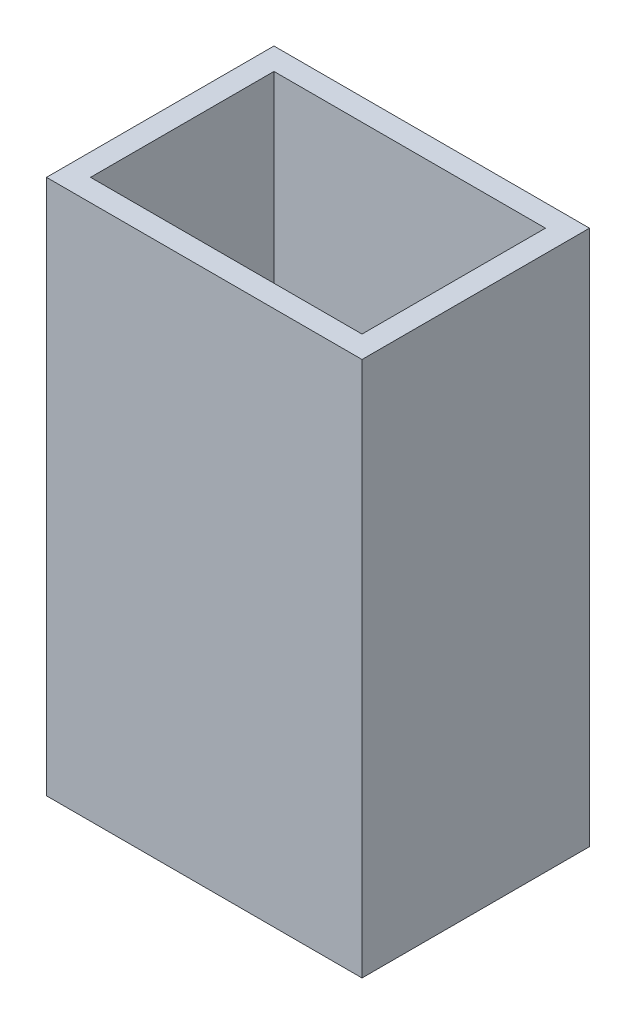
from build123d import *

# Parameters (mm, degrees)
SKETCH1_W            = 43
SKETCH1_H            = 31
BOSS_EXTRUDE1_DEPTH  = 3
BOSS_EXTRUDE2_START  = 3
SKETCH1_3_W          = 43
SKETCH1_3_H          = 31
SKETCH1_3_W_2        = 37
SKETCH1_3_H_2        = 25
BOSS_EXTRUDE2_DEPTH  = 70
M3_CLEARANCE_HOLE1_D = 3.4


with BuildPart() as part:
    # Sketch1 → Boss-Extrude1 (new body)
    with BuildSketch(Plane(origin=(0, 0, 0), x_dir=(1, 0, 0), z_dir=(0, 1, 0))):
        Rectangle(SKETCH1_W, SKETCH1_H)
    extrude(amount=BOSS_EXTRUDE1_DEPTH)

    # Sketch1_3 → Boss-Extrude2 (add)
    with BuildSketch(Plane(origin=(0, 0, 0), x_dir=(1, 0, 0), z_dir=(0, 1, 0)).offset(BOSS_EXTRUDE2_START)):
        Rectangle(SKETCH1_3_W, SKETCH1_3_H)
        Rectangle(SKETCH1_3_W_2, SKETCH1_3_H_2, mode=Mode.SUBTRACT)
    extrude(amount=BOSS_EXTRUDE2_DEPTH)

    # M3 Clearance Hole1 (through all)
    with Locations(Plane(origin=(0, 3, 0), x_dir=(1, 0, 0), z_dir=(0, 1, 0))):
        with Locations((-12.5, 9.5), (12.5, 9.5), (12.5, -9.5), (-12.5, -9.5)):
            Hole(M3_CLEARANCE_HOLE1_D / 2)


solid = part.part
